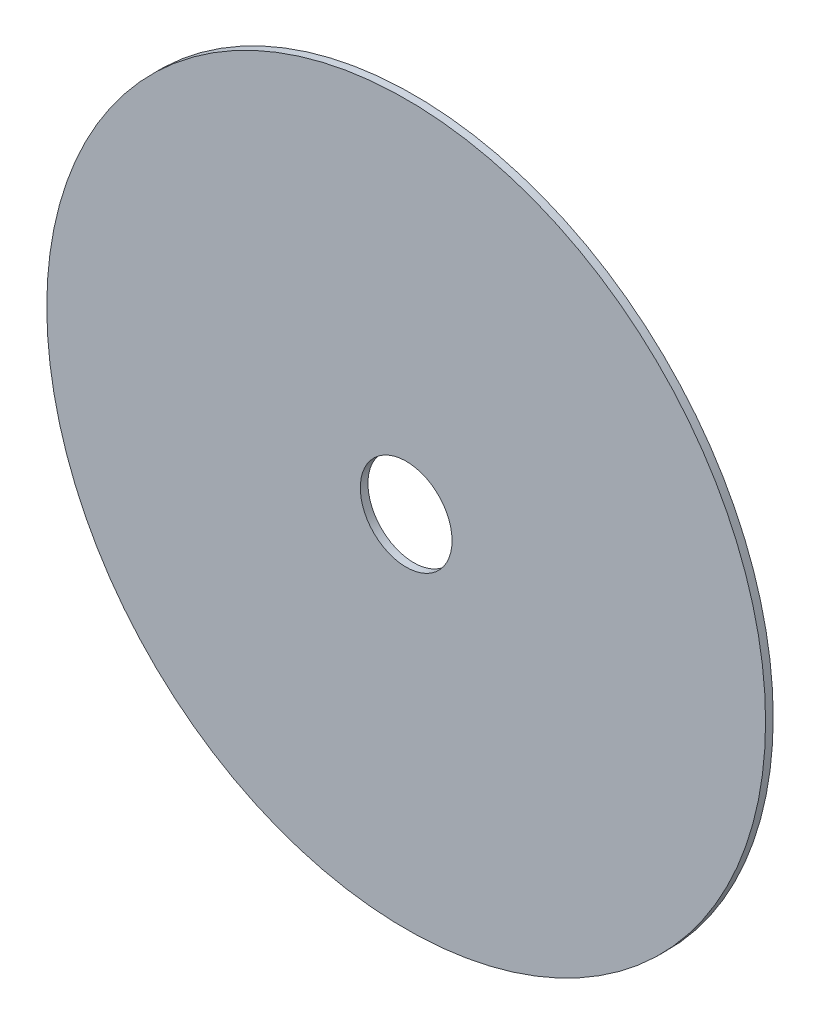
from build123d import *

# Parameters (mm, degrees)
SKETCH1_R           = 59.69
SKETCH1_R_2         = 7.62
BOSS_EXTRUDE1_DEPTH = 1.27


with BuildPart() as part:
    # Sketch1 → Boss-Extrude1 (new body)
    with BuildSketch(Plane.XY):
        Circle(SKETCH1_R)
        Circle(SKETCH1_R_2, mode=Mode.SUBTRACT)
    extrude(amount=BOSS_EXTRUDE1_DEPTH)


solid = part.part
